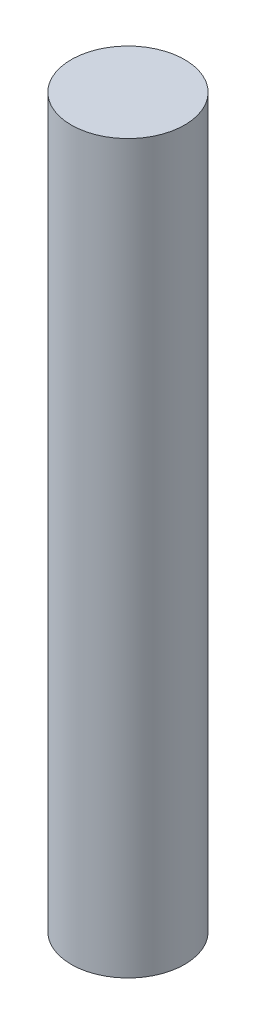
from build123d import *

# Parameters (mm, degrees)
SKETCH1_R           = 3.9
BOSS_EXTRUDE1_DEPTH = 50


with BuildPart() as part:
    # Sketch1 → Boss-Extrude1 (new body)
    with BuildSketch(Plane(origin=(0, 0, 0), x_dir=(1, 0, 0), z_dir=(0, 1, 0))):
        Circle(SKETCH1_R)
    extrude(amount=BOSS_EXTRUDE1_DEPTH)


solid = part.part
